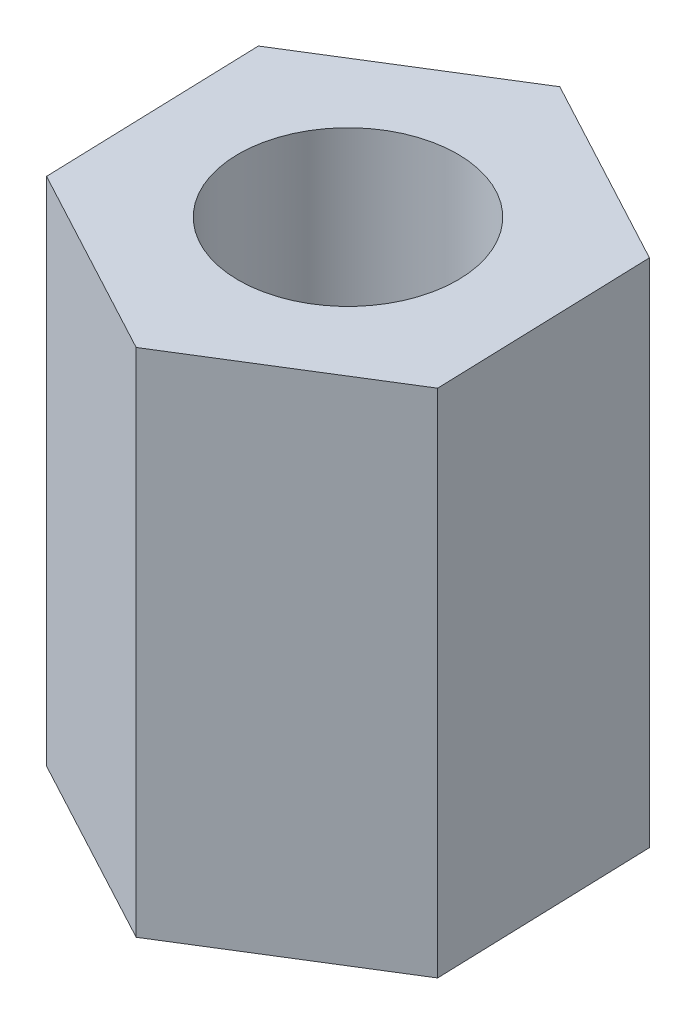
from build123d import *

# Parameters (mm, degrees)
SKETCH1_R           = 1.5
BOSS_EXTRUDE2_DEPTH = 7


with BuildPart() as part:
    # Sketch1 → Boss-Extrude2 (new body)
    with BuildSketch(Plane(origin=(0, 0, 0), x_dir=(1, 0, 0), z_dir=(0, 1, 0))):
        Polygon((2.548902001, 1.582118387), (-0.095703715, 2.998473078), (-2.644605716, 1.416354691), (-2.548902001, -1.582118387), (0.095703715, -2.998473078), (2.644605716, -1.416354691), align=None)
        Circle(SKETCH1_R, mode=Mode.SUBTRACT)
    extrude(amount=BOSS_EXTRUDE2_DEPTH)


solid = part.part
